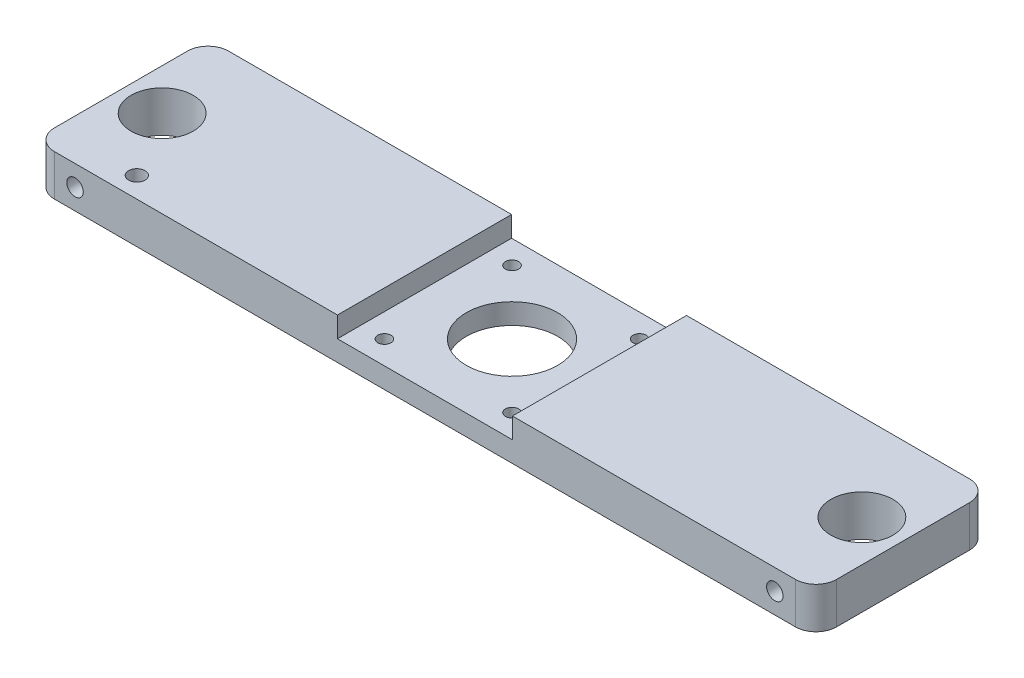
from build123d import *

# Parameters (mm, degrees)
SKETCH_1_W          = 190
SKETCH_1_H          = 42.3
EXTRUDE_1_DEPTH     = 10
SKETCH_2_W          = 42.5
SKETCH_2_H          = 77.05305565
CUT_EXTRUDE_1_DEPTH = 5
SKETCH_3_R          = 1.6
SKETCH_3_R_2        = 11.1
CUT_EXTRUDE_2_DEPTH = 6
SKETCH_4_R          = 7.55
CUT_EXTRUDE_3_DEPTH = 11
FILLET_1_R          = 5
CUT_EXTRUDE_4_REACH = 44.3
SKETCH_5_R          = 2
SKETCH_6_R          = 2
CUT_EXTRUDE_5_DEPTH = 11.0000001


with BuildPart() as part:
    # 草图1 → 凸台-拉伸1 (new body)
    with BuildSketch(Plane(origin=(0, 0, 0), x_dir=(1, 0, 0), z_dir=(0, 1, 0))):
        Rectangle(SKETCH_1_W, SKETCH_1_H)
    extrude(amount=EXTRUDE_1_DEPTH)

    # 草图2 → 切除-拉伸1 (cut)
    with BuildSketch(Plane(origin=(0, 10, 0), x_dir=(1, 0, 0), z_dir=(0, 1, 0))):
        Rectangle(SKETCH_2_W, SKETCH_2_H)
    extrude(amount=-CUT_EXTRUDE_1_DEPTH, mode=Mode.SUBTRACT)

    # 草图3 → 切除-拉伸2 (cut, through all)
    with BuildSketch(Plane(origin=(0, 5, 0), x_dir=(1, 0, 0), z_dir=(0, 1, 0))):
        with Locations((-15.5, 15.5)):
            Circle(SKETCH_3_R)
        with Locations((15.5, 15.5)):
            Circle(SKETCH_3_R)
        with Locations((15.5, -15.5)):
            Circle(SKETCH_3_R)
        with Locations((-15.5, -15.5)):
            Circle(SKETCH_3_R)
        Circle(SKETCH_3_R_2)
    extrude(amount=-CUT_EXTRUDE_2_DEPTH, mode=Mode.SUBTRACT)

    # 草图4 → 切除-拉伸3 (cut, through all)
    with BuildSketch(Plane(origin=(0, 10, 0), x_dir=(1, 0, 0), z_dir=(0, 1, 0))):
        with Locations((-85, 0)):
            Circle(SKETCH_4_R)
        with Locations((85, 0)):
            Circle(SKETCH_4_R)
    extrude(amount=-CUT_EXTRUDE_3_DEPTH, mode=Mode.SUBTRACT)

    # 圆角1
    fillet_1_edges = [part.edges().sort_by_distance(p)[0] for p in [
        (95, 5, 21.15),
        (-95, 5, 21.15),
        (-95, 5, -21.15),
        (95, 5, -21.15),
    ]]
    fillet(fillet_1_edges, radius=FILLET_1_R)

    # 草图5 → 切除-拉伸4 (cut, up to next)
    with BuildSketch(Plane.XY.offset(21.15), mode=Mode.PRIVATE) as cut_extrude_4_sk1:
        with Locations((85, 5)):
            Circle(SKETCH_5_R)
    cut_extrude_4_tool1 = extrude(cut_extrude_4_sk1.sketch, amount=-CUT_EXTRUDE_4_REACH, mode=Mode.PRIVATE) & part.part
    add(cut_extrude_4_tool1.solids().sort_by_distance((85, 5, 21.15))[0], mode=Mode.SUBTRACT)
    # 草图5 → 切除-拉伸4 (cut, up to next)
    with BuildSketch(Plane.XY.offset(21.15), mode=Mode.PRIVATE) as cut_extrude_4_sk2:
        with Locations((-85, 5)):
            Circle(SKETCH_5_R)
    cut_extrude_4_tool2 = extrude(cut_extrude_4_sk2.sketch, amount=-CUT_EXTRUDE_4_REACH, mode=Mode.PRIVATE) & part.part
    add(cut_extrude_4_tool2.solids().sort_by_distance((-85, 5, 21.15))[0], mode=Mode.SUBTRACT)

    # 草图6 → 切除-拉伸5 (cut, through all)
    with BuildSketch(Plane(origin=(0, 10, 0), x_dir=(1, 0, 0), z_dir=(0, 1, 0))):
        with Locations((-75, -16.15)):
            Circle(SKETCH_6_R)
    extrude(amount=-CUT_EXTRUDE_5_DEPTH, mode=Mode.SUBTRACT)


solid = part.part
